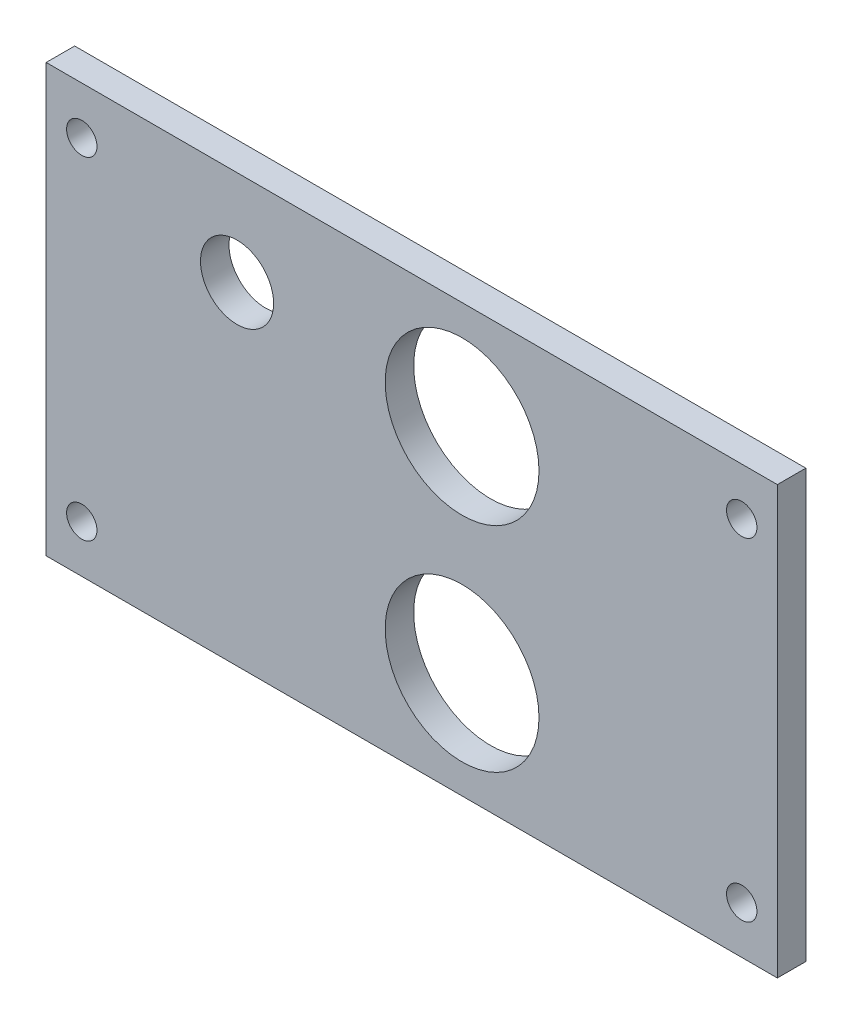
from build123d import *

# Parameters (mm, degrees)
CROQUIS1_W              = 77
CROQUIS1_H              = 45
SALIENTE_EXTRUIR1_DEPTH = 3
CORTAR_EXTRUIR1_REACH   = 5
CROQUIS2_R              = 8.1
CROQUIS2_R_2            = 3.85
CROQUIS2_R_3            = 1.6


with BuildPart() as part:
    # Croquis1 → Saliente-Extruir1 (new body)
    with BuildSketch(Plane.XY):
        Rectangle(CROQUIS1_W, CROQUIS1_H)
    extrude(amount=SALIENTE_EXTRUIR1_DEPTH)

    # Croquis2 → Cortar-Extruir1 (cut, up to next)
    with BuildSketch(Plane.XY.offset(3), mode=Mode.PRIVATE) as cortar_extruir1_sk1:
        with Locations((5.3, 11.2)):
            Circle(CROQUIS2_R)
    cortar_extruir1_tool1 = extrude(cortar_extruir1_sk1.sketch, amount=-CORTAR_EXTRUIR1_REACH, mode=Mode.PRIVATE) & part.part
    add(cortar_extruir1_tool1.solids().sort_by_distance((5.3, 11.2, 3))[0], mode=Mode.SUBTRACT)
    # Croquis2 → Cortar-Extruir1 (cut, up to next)
    with BuildSketch(Plane.XY.offset(3), mode=Mode.PRIVATE) as cortar_extruir1_sk2:
        with Locations((5.3, -11.3)):
            Circle(CROQUIS2_R)
    cortar_extruir1_tool2 = extrude(cortar_extruir1_sk2.sketch, amount=-CORTAR_EXTRUIR1_REACH, mode=Mode.PRIVATE) & part.part
    add(cortar_extruir1_tool2.solids().sort_by_distance((5.3, -11.3, 3))[0], mode=Mode.SUBTRACT)
    # Croquis2 → Cortar-Extruir1 (cut, up to next)
    with BuildSketch(Plane.XY.offset(3), mode=Mode.PRIVATE) as cortar_extruir1_sk3:
        with Locations((-18.4, 12.5)):
            Circle(CROQUIS2_R_2)
    cortar_extruir1_tool3 = extrude(cortar_extruir1_sk3.sketch, amount=-CORTAR_EXTRUIR1_REACH, mode=Mode.PRIVATE) & part.part
    add(cortar_extruir1_tool3.solids().sort_by_distance((-18.4, 12.5, 3))[0], mode=Mode.SUBTRACT)
    # Croquis2 → Cortar-Extruir1 (cut, up to next)
    with BuildSketch(Plane.XY.offset(3), mode=Mode.PRIVATE) as cortar_extruir1_sk4:
        with Locations((-34.75, 17.5)):
            Circle(CROQUIS2_R_3)
    cortar_extruir1_tool4 = extrude(cortar_extruir1_sk4.sketch, amount=-CORTAR_EXTRUIR1_REACH, mode=Mode.PRIVATE) & part.part
    add(cortar_extruir1_tool4.solids().sort_by_distance((-34.75, 17.5, 3))[0], mode=Mode.SUBTRACT)
    # Croquis2 → Cortar-Extruir1 (cut, up to next)
    with BuildSketch(Plane.XY.offset(3), mode=Mode.PRIVATE) as cortar_extruir1_sk5:
        with Locations((34.75, 17.5)):
            Circle(CROQUIS2_R_3)
    cortar_extruir1_tool5 = extrude(cortar_extruir1_sk5.sketch, amount=-CORTAR_EXTRUIR1_REACH, mode=Mode.PRIVATE) & part.part
    add(cortar_extruir1_tool5.solids().sort_by_distance((34.75, 17.5, 3))[0], mode=Mode.SUBTRACT)
    # Croquis2 → Cortar-Extruir1 (cut, up to next)
    with BuildSketch(Plane.XY.offset(3), mode=Mode.PRIVATE) as cortar_extruir1_sk6:
        with Locations((34.75, -17.5)):
            Circle(CROQUIS2_R_3)
    cortar_extruir1_tool6 = extrude(cortar_extruir1_sk6.sketch, amount=-CORTAR_EXTRUIR1_REACH, mode=Mode.PRIVATE) & part.part
    add(cortar_extruir1_tool6.solids().sort_by_distance((34.75, -17.5, 3))[0], mode=Mode.SUBTRACT)
    # Croquis2 → Cortar-Extruir1 (cut, up to next)
    with BuildSketch(Plane.XY.offset(3), mode=Mode.PRIVATE) as cortar_extruir1_sk7:
        with Locations((-34.75, -17.5)):
            Circle(CROQUIS2_R_3)
    cortar_extruir1_tool7 = extrude(cortar_extruir1_sk7.sketch, amount=-CORTAR_EXTRUIR1_REACH, mode=Mode.PRIVATE) & part.part
    add(cortar_extruir1_tool7.solids().sort_by_distance((-34.75, -17.5, 3))[0], mode=Mode.SUBTRACT)


solid = part.part
